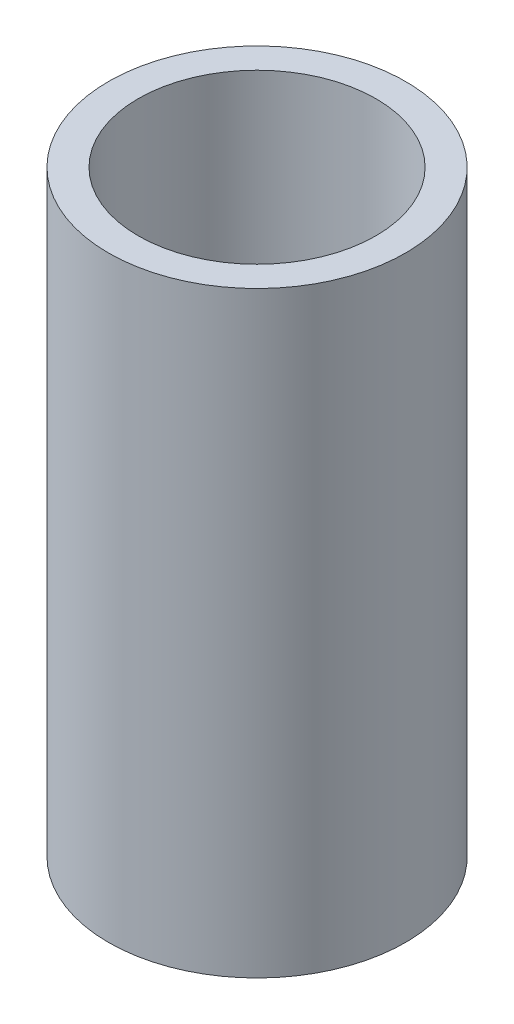
from build123d import *

# Parameters (mm, degrees)
SKETCH1_R      = 1.984375
SKETCH1_R_2    = 1.5875
EXTRUDE1_DEPTH = 7.9756


with BuildPart() as part:
    # Sketch1 → Extrude1 (new body)
    with BuildSketch(Plane(origin=(0, 0, 0), x_dir=(1, 0, 0), z_dir=(0, 1, 0))):
        Circle(SKETCH1_R)
        Circle(SKETCH1_R_2, mode=Mode.SUBTRACT)
    extrude(amount=EXTRUDE1_DEPTH)


solid = part.part
